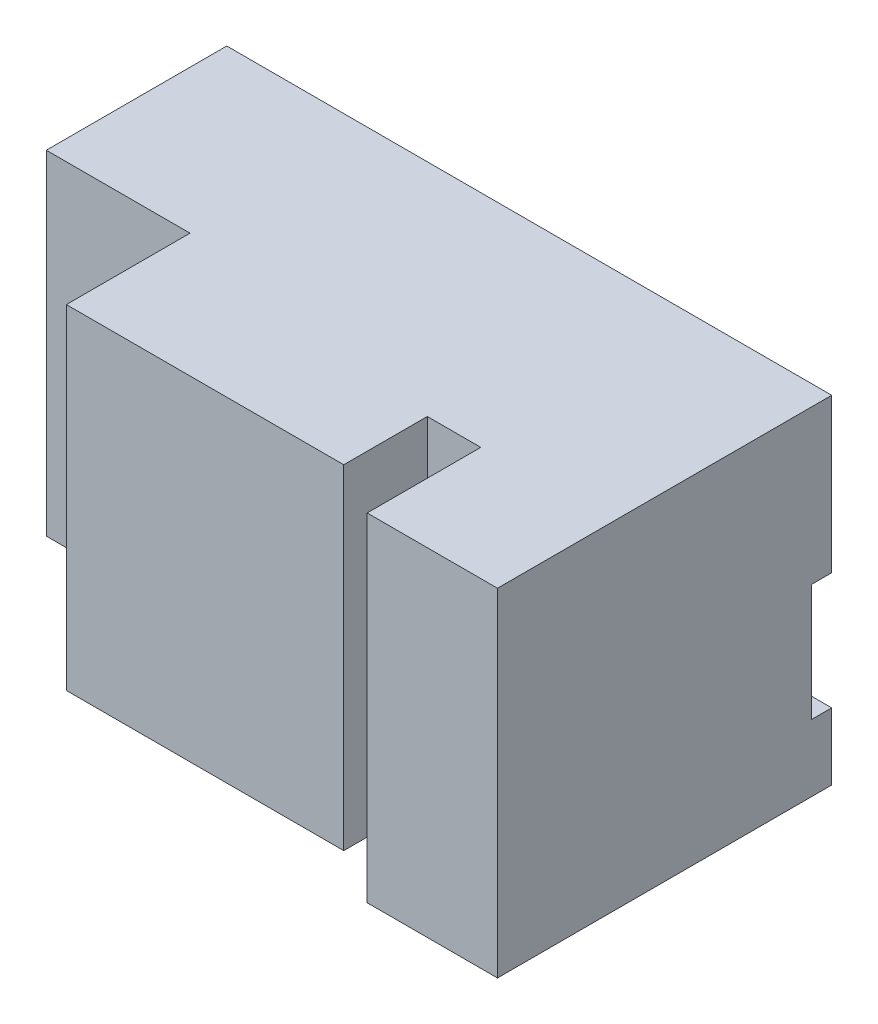
from build123d import *

# Parameters (mm, degrees)
SKETCH2_W           = 43
SKETCH2_H           = 100
BOSS_EXTRUDE1_DEPTH = 54
SKETCH3_W           = 83
SKETCH3_H           = 100
BOSS_EXTRUDE2_DEPTH = 91
SKETCH4_W           = 16
SKETCH4_H           = 100
BOSS_EXTRUDE3_DEPTH = 66
SKETCH6_W           = 39
SKETCH6_H           = 100
BOSS_EXTRUDE4_DEPTH = 100
SKETCH5_W           = 6
SKETCH5_H           = 35
CUT_EXTRUDE1_DEPTH  = 200
SKETCH7_W           = 39
SKETCH7_H           = 100
BOSS_EXTRUDE5_DEPTH = 1


with BuildPart() as part:
    # Sketch2 → Boss-Extrude1 (new body)
    with BuildSketch(Plane.XY):
        Rectangle(SKETCH2_W, SKETCH2_H)
    extrude(amount=BOSS_EXTRUDE1_DEPTH)

    # Sketch3 → Boss-Extrude2 (add)
    with BuildSketch(Plane.XY):
        with Locations((63, 0)):
            Rectangle(SKETCH3_W, SKETCH3_H)
    extrude(amount=BOSS_EXTRUDE2_DEPTH)

    # Sketch4 → Boss-Extrude3 (add)
    with BuildSketch(Plane.XY):
        with Locations((112.5, 0)):
            Rectangle(SKETCH4_W, SKETCH4_H)
    extrude(amount=BOSS_EXTRUDE3_DEPTH)

    # Sketch6 → Boss-Extrude4 (add)
    with BuildSketch(Plane.XY):
        with Locations((140, 0)):
            Rectangle(SKETCH6_W, SKETCH6_H)
    extrude(amount=BOSS_EXTRUDE4_DEPTH)

    # Sketch5 → Cut-Extrude1 (cut)
    with BuildSketch(Plane(origin=(159.5, 0, 0), x_dir=(0, 0, -1), z_dir=(1, 0, 0))):
        with Locations((-3, -13.5)):
            Rectangle(SKETCH5_W, SKETCH5_H)
    extrude(amount=-CUT_EXTRUDE1_DEPTH, mode=Mode.SUBTRACT)

    # Sketch7 → Boss-Extrude5 (add)
    with BuildSketch(Plane.XZ.offset(50)):
        with Locations((140, 50)):
            Rectangle(SKETCH7_W, SKETCH7_H)
    extrude(amount=BOSS_EXTRUDE5_DEPTH)


solid = part.part
